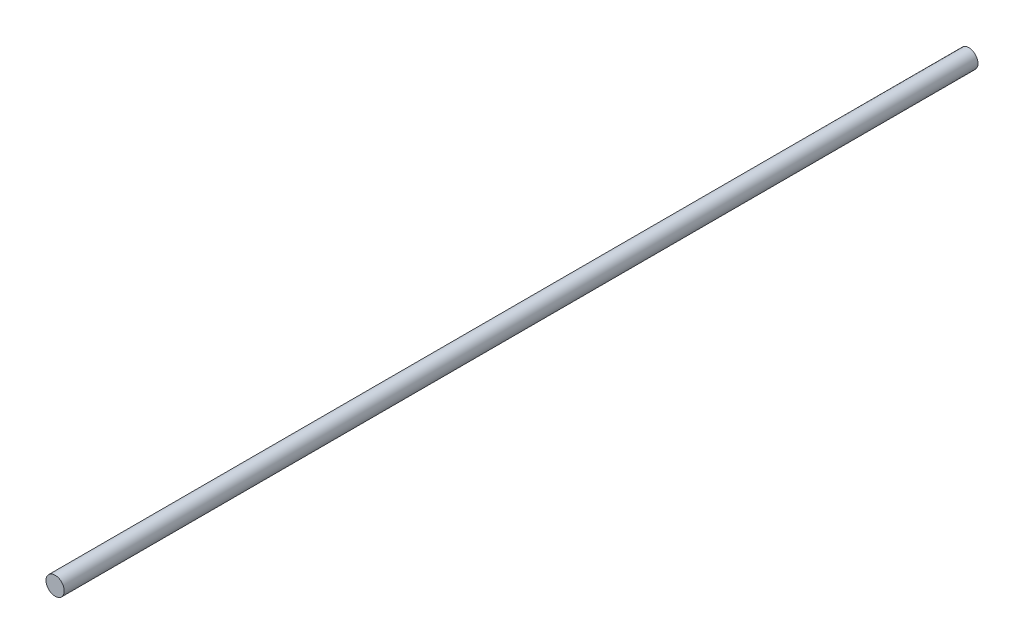
from build123d import *

# Parameters (mm, degrees)
SKETCH1_R           = 4
BOSS_EXTRUDE1_DEPTH = 400


with BuildPart() as part:
    # Sketch1 → Boss-Extrude1 (new body)
    with BuildSketch(Plane.XY):
        Circle(SKETCH1_R)
    extrude(amount=BOSS_EXTRUDE1_DEPTH)


solid = part.part
